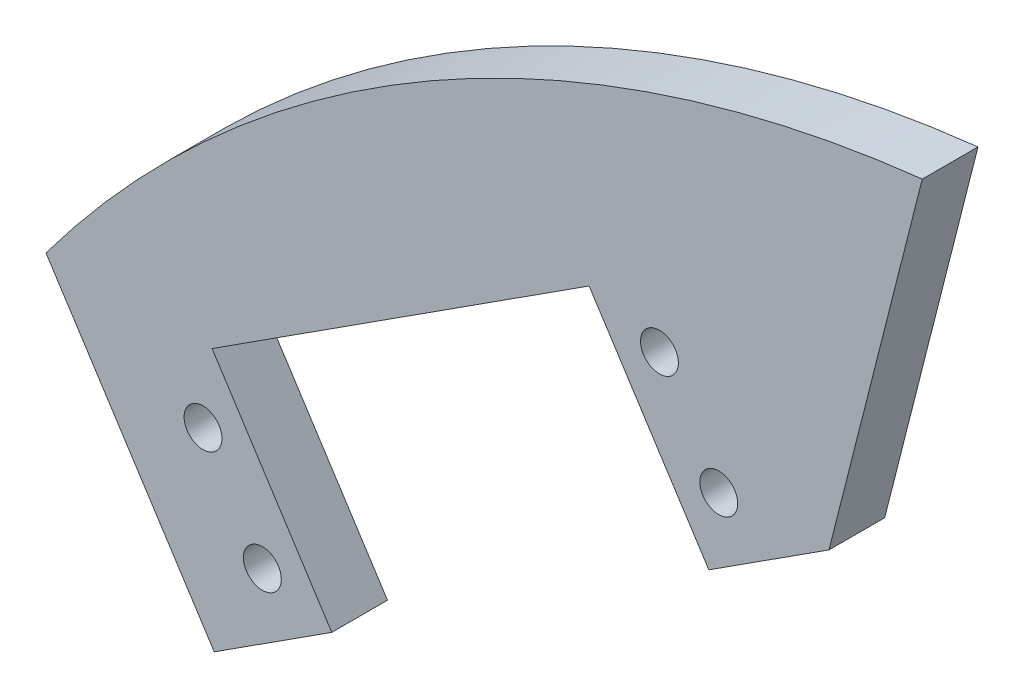
from build123d import *

# Parameters (mm, degrees)
BOSS_EXTRUDE1_DEPTH = 5.08
SKETCH2_R           = 1.7272
CUT_EXTRUDE1_DEPTH  = 5.08


with BuildPart() as part:
    # Sketch1 → Boss-Extrude1 (new body)
    with BuildSketch(Plane.XY):
        with BuildLine():
            Line((-15.343524861, 23.838622958), (0, 0))
            Line((0, 0), (56.065565283, 36.086119416))
            Line((56.065565283, 36.086119416), (64.573765087, 69.628973221))
            ThreePointArc((64.573765087, 69.628973221), (19.853616616, 55.043986881), (-15.343524861, 23.838622958))
        make_face()
    extrude(amount=BOSS_EXTRUDE1_DEPTH)

    # Sketch2 → Cut-Extrude1 (cut)
    with BuildSketch(Plane.XY.offset(5.08)):
        with Locations((46.012387455, 35.57370741)):
            Circle(SKETCH2_R)
        with Locations((-1.023333215, 17.191896262)):
            Circle(SKETCH2_R)
        with Locations((4.388908167, 8.783112568)):
            Circle(SKETCH2_R)
        with Locations((40.600146073, 43.982491105)):
            Circle(SKETCH2_R)
        Polygon((10.799924344, 6.773067648), (45.186804384, 28.905887557), (34.189129896, 45.992536024), (-0.197750144, 23.859716115), align=None)
    extrude(amount=-CUT_EXTRUDE1_DEPTH, mode=Mode.SUBTRACT)


solid = part.part
